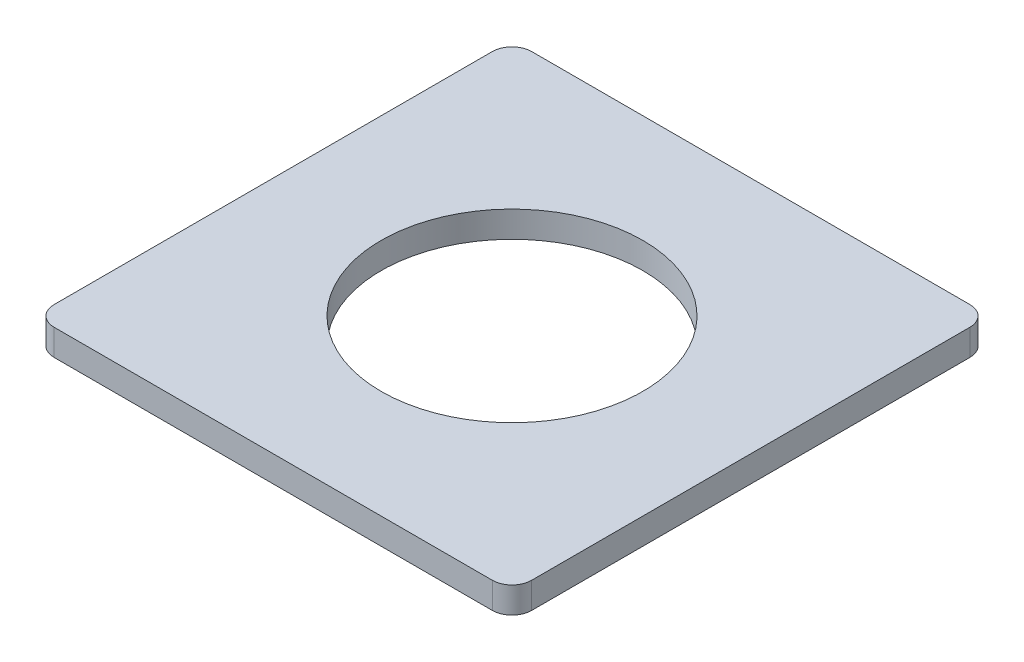
from build123d import *

# Parameters (mm, degrees)
SKETCH1_W           = 18.542
SKETCH1_H           = 18.542
SKETCH1_R           = 5.08
BOSS_EXTRUDE1_DEPTH = 1.016
FILLET1_R           = 0.762


with BuildPart() as part:
    # Sketch1 → Boss-Extrude1 (new body)
    with BuildSketch(Plane(origin=(0, 0, 0), x_dir=(1, 0, 0), z_dir=(0, 1, 0))):
        Rectangle(SKETCH1_W, SKETCH1_H)
        Circle(SKETCH1_R, mode=Mode.SUBTRACT)
    extrude(amount=BOSS_EXTRUDE1_DEPTH)

    # Fillet1
    fillet1_edges = [part.edges().sort_by_distance(p)[0] for p in [
        (9.271, 0.508, 9.271),
        (-9.271, 0.508, 9.271),
        (-9.271, 0.508, -9.271),
        (9.271, 0.508, -9.271),
    ]]
    fillet(fillet1_edges, radius=FILLET1_R)


solid = part.part
